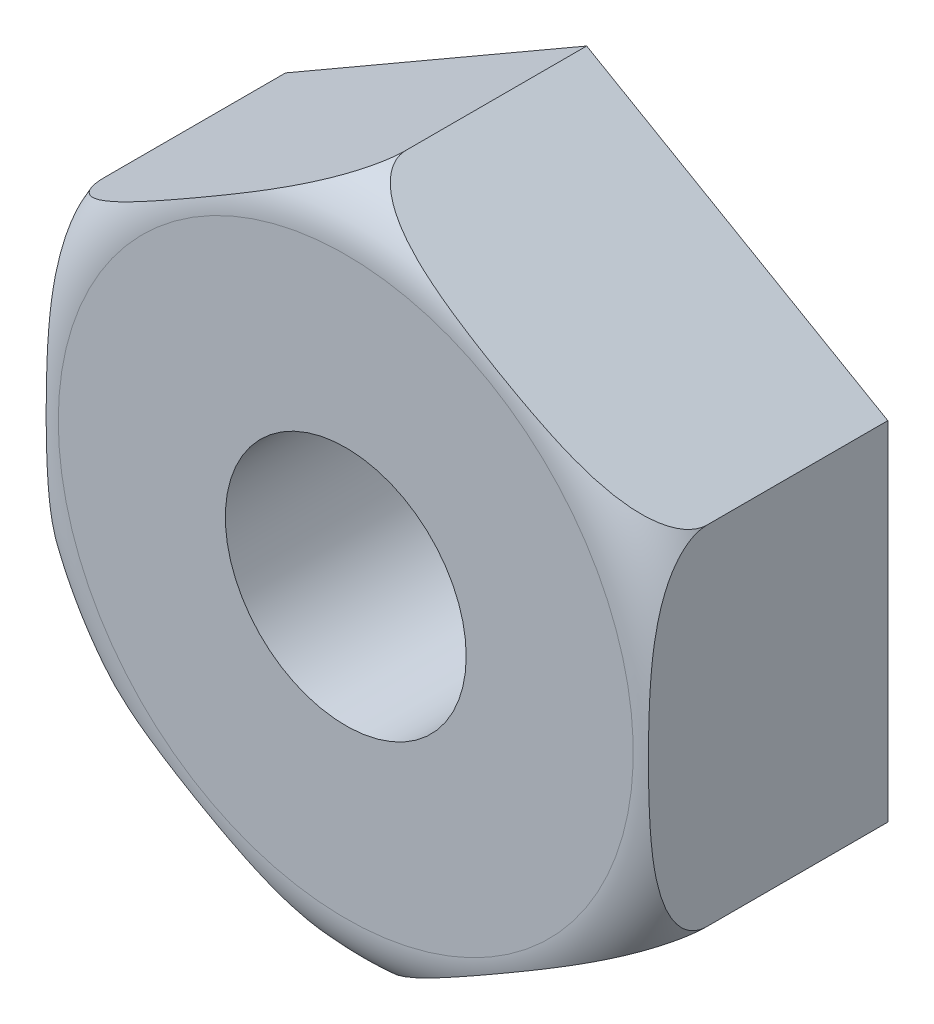
from build123d import *

# Parameters (mm, degrees)
BOSS_EXTRUDE1_DEPTH = 2
SKETCH4_R           = 2
CUT_EXTRUDE1_DEPTH  = 10


with BuildPart() as part:
    # Sketch1 → Boss-Extrude1 (new body, symmetric)
    with BuildSketch(Plane.XY):
        Polygon((0, -5.773502692), (5, -2.886751346), (5, 2.886751346), (0, 5.773502692), (-5, 2.886751346), (-5, -2.886751346), align=None)
    extrude(amount=BOSS_EXTRUDE1_DEPTH, both=True)

    # Sketch3 → Cut-Revolve2 (revolve, cut)
    with BuildSketch(Plane(origin=(0, 0, 0), x_dir=(0, 0, -1), z_dir=(1, 0, 0))):
        with BuildLine():
            Line((-2, 4.773502692), (-3.338978682, 5.429088281))
            Line((-3.338978682, 5.429088281), (-2.142437664, 6.332858624))
            Line((-2.142437664, 6.332858624), (-1, 5.773502692))
            ThreePointArc((-1, 5.773502692), (-1.707106781, 5.480609473), (-2, 4.773502692))
        make_face()
    revolve(axis=Axis((0, 0, 0), (0, 0, 1)), mode=Mode.SUBTRACT)

    # Sketch4 → Cut-Extrude1 (cut)
    with BuildSketch(Plane.XY.offset(2)):
        Circle(SKETCH4_R)
    extrude(amount=-CUT_EXTRUDE1_DEPTH, mode=Mode.SUBTRACT)


solid = part.part
